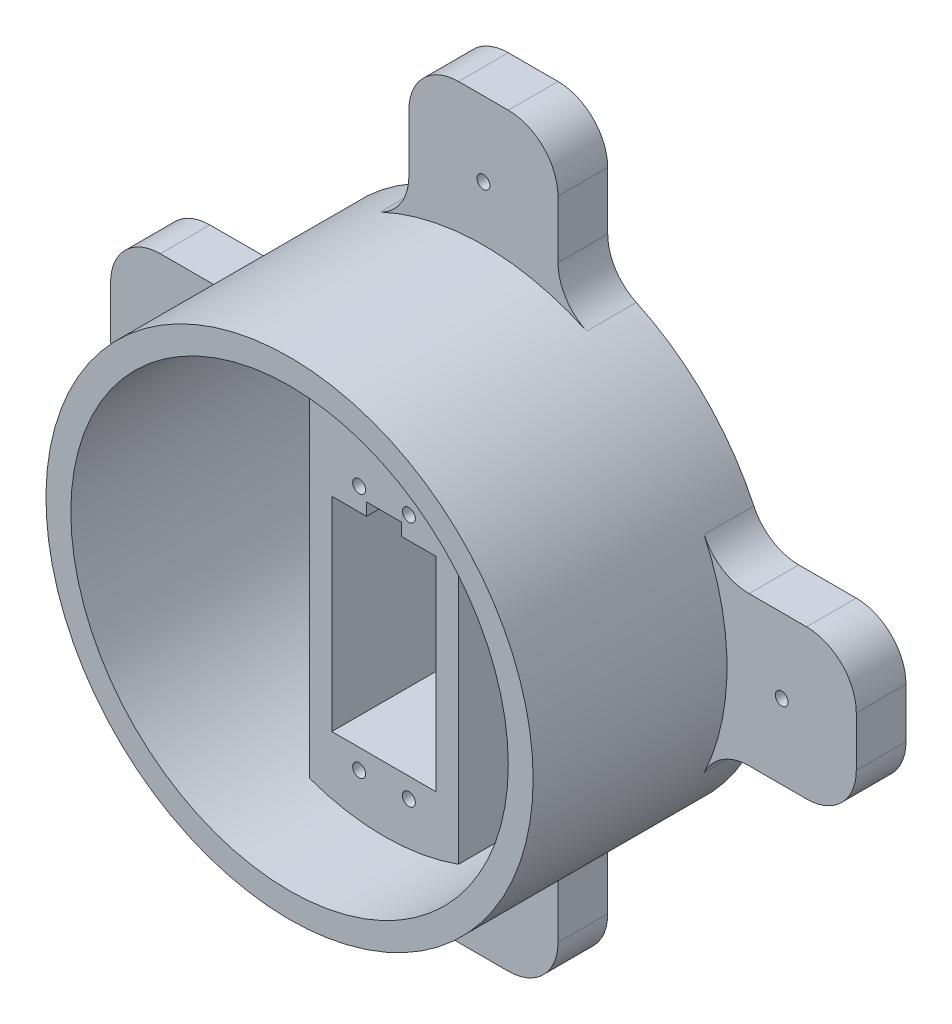
from build123d import *

# Parameters (mm, degrees)
SZKIC1_R                    = 49
SZKIC1_R_2                  = 44
DODANIE_WYCI_GNI_CIE1_DEPTH = 49
DODANIE_WYCI_GNI_CIE2_DEPTH = 30
SZKIC3_W                    = 21
SZKIC3_H                    = 41
WYTNIJ_WYCI_GNI_CIE1_DEPTH  = 30
WYTNIJ_WYCI_GNI_CIE2_DEPTH  = 20
OTW_R_POD_RUB_M21_D         = 2.6
WYTNIJ_WYCI_GNI_CIE3_REACH  = 77.512
SZKIC8_W                    = 7
SZKIC8_H                    = 5
DODANIE_WYCI_GNI_CIE3_DEPTH = 10
OTW_R_POD_RUB_M22_D         = 2.6
SZYK_KO_OWY1_COUNT          = 4
ZAOKR_GLENIE1_R             = 10


with BuildPart() as part:
    # Szkic1 → Dodanie-wyciągnięcie1 (new body)
    with BuildSketch(Plane.XY):
        Circle(SZKIC1_R)
        Circle(SZKIC1_R_2, mode=Mode.SUBTRACT)
    extrude(amount=DODANIE_WYCI_GNI_CIE1_DEPTH)

    # Szkic2 → Dodanie-wyciągnięcie2 (add)
    with BuildSketch(Plane.XY):
        with BuildLine():
            Line((15, 46.647615159), (15, -46.647615159))
            ThreePointArc((15, -46.647615159), (0, -49), (-15, -46.647615159))
            Line((-15, -46.647615159), (-15, 46.647615159))
            ThreePointArc((-15, 46.647615159), (0, 49), (15, 46.647615159))
        make_face()
    extrude(amount=DODANIE_WYCI_GNI_CIE2_DEPTH)

    # Szkic3 → Wytnij-wyciągnięcie1 (cut)
    with BuildSketch(Plane.XY.offset(30)):
        with Locations((0, -10.5)):
            Rectangle(SZKIC3_W, SZKIC3_H)
    extrude(amount=-WYTNIJ_WYCI_GNI_CIE1_DEPTH, mode=Mode.SUBTRACT)

    # Szkic5 → Wytnij-wyciągnięcie2 (cut)
    with BuildSketch(Plane(origin=(0, 0, 0), x_dir=(-1, 0, 0), z_dir=(0, 0, -1))):
        Polygon((6.154700538, -33), (3.845299462, -33), (2.690598923, -35), (3.845299462, -37), (6.154700538, -37), (7.309401077, -35), align=None)
    wytnij_wyci_gni_cie2 = extrude(amount=-WYTNIJ_WYCI_GNI_CIE2_DEPTH, mode=Mode.SUBTRACT)

    # Szkic-szyk1: Wytnij-wyciągnięcie2 at 3 more places
    with Locations((0, 49.5, 0), (10, 49.5, 0), (10, 0, 0)):
        add(wytnij_wyci_gni_cie2, mode=Mode.SUBTRACT)

    # Otwór pod śrubę M21 (through all)
    with Locations(Plane(origin=(0, 0, 20), x_dir=(-1, 0, 0), z_dir=(0, 0, -1))):
        with Locations((-5, 14.5)):
            otw_r_pod_rub_m21 = Hole(OTW_R_POD_RUB_M21_D / 2)

    # Szkic-szyk2: Otwór pod śrubę M21 at 3 more places
    with Locations((-10, 0, 0), (0, -49.5, 0), (-10, -49.5, 0)):
        add(otw_r_pod_rub_m21, mode=Mode.SUBTRACT)

    # Szkic8 → Wytnij-wyciągnięcie3 (cut, up to next)
    with BuildSketch(Plane.XY.offset(30), mode=Mode.PRIVATE) as wytnij_wyci_gni_cie3_sk1:
        with Locations((0, 10)):
            Rectangle(SZKIC8_W, SZKIC8_H)
    wytnij_wyci_gni_cie3_tool1 = extrude(wytnij_wyci_gni_cie3_sk1.sketch, amount=-WYTNIJ_WYCI_GNI_CIE3_REACH, mode=Mode.PRIVATE) & part.part
    add(wytnij_wyci_gni_cie3_tool1.solids().sort_by_distance((0, 10, 30))[0], mode=Mode.SUBTRACT)

    # Szkic9 → Dodanie-wyciągnięcie3 (add)
    with BuildSketch(Plane(origin=(0, 0, 0), x_dir=(-1, 0, 0), z_dir=(0, 0, -1))):
        with BuildLine():
            Line((-75, -15), (-41.36423576, -15))
            ThreePointArc((-41.36423576, -15), (-44, 0), (-41.36423576, 15))
            Line((-41.36423576, 15), (-75, 15))
            Line((-75, 15), (-75, -15))
        make_face()
    dodanie_wyci_gni_cie3 = extrude(amount=-DODANIE_WYCI_GNI_CIE3_DEPTH)

    # Otwór pod śrubę M22 (through all)
    with Locations(Plane.XY.offset(10)):
        with Locations((60, 0)):
            otw_r_pod_rub_m22 = Hole(OTW_R_POD_RUB_M22_D / 2)

    # Szyk kołowy1: Dodanie-wyciągnięcie3, Otwór pod śrubę M22 ×4 about axis
    szyk_ko_owy1_axis = Axis((0, 0, 0), (0, 0, 1))
    add([dodanie_wyci_gni_cie3.rotate(szyk_ko_owy1_axis, i * 360 / SZYK_KO_OWY1_COUNT) for i in range(1, SZYK_KO_OWY1_COUNT)])
    add([otw_r_pod_rub_m22.rotate(szyk_ko_owy1_axis, i * 360 / SZYK_KO_OWY1_COUNT) for i in range(1, SZYK_KO_OWY1_COUNT)], mode=Mode.SUBTRACT)

    # Zaokrąglenie1
    zaokr_glenie1_edges = [part.edges().sort_by_distance(p)[0] for p in [
        (46.647615159, -15, 5),
        (46.647615159, 15, 5),
        (75, 15, 5),
        (75, -15, 5),
        (15, -46.647615159, 5),
        (15, -75, 5),
        (-15, -75, 5),
        (-15, -46.647615159, 5),
        (-46.647615159, -15, 5),
        (-75, -15, 5),
        (-75, 15, 5),
        (-46.647615159, 15, 5),
        (-15, 46.647615159, 5),
        (-15, 75, 5),
        (15, 75, 5),
        (15, 46.647615159, 5),
    ]]
    fillet(zaokr_glenie1_edges, radius=ZAOKR_GLENIE1_R)


solid = part.part
